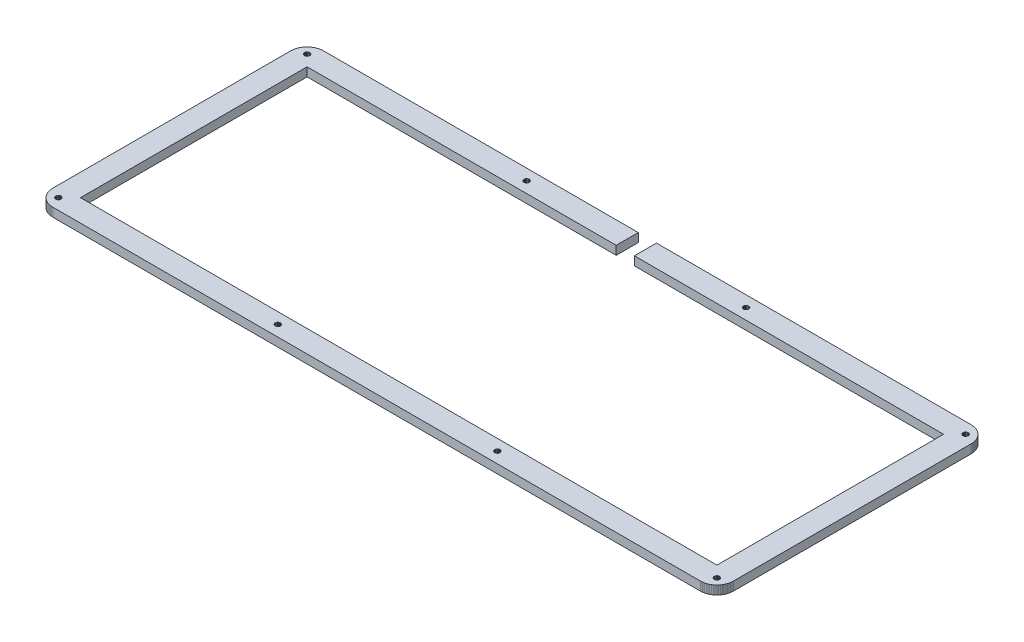
from build123d import *

# Parameters (mm, degrees)
BOSS_EXTRUDE1_DEPTH = 4.7625


with BuildPart() as part:
    # Sketch1 → Boss-Extrude1 (new body)
    with BuildSketch(Plane(origin=(0, 0, 0), x_dir=(1, 0, 0), z_dir=(0, 1, 0))):
        Polygon((180.976, 147.968), (180.976, 135.919), (12.1447, 135.919), (12.1447, 12.1405), (359.759, 12.1405), (359.759, 135.919), (190.926, 135.919), (190.926, 147.967), (362.807, 147.967), (363.513, 147.941), (364.215, 147.857), (364.91, 147.719), (365.591, 147.527), (366.254, 147.282), (366.896, 146.987), (367.51, 146.641), (368.099, 146.25), (368.653, 145.812), (369.171, 145.331), (369.651, 144.812), (370.089, 144.259), (370.48, 143.67), (370.826, 143.053), (371.122, 142.412), (371.369, 141.749), (371.56, 141.07), (371.697, 140.375), (371.778, 139.674), (371.807, 138.967), (371.807, 9.09091), (371.778, 8.38535), (371.697, 7.68396), (371.56, 6.99079), (371.369, 6.31003), (371.122, 5.6472), (370.826, 5.00641), (370.48, 4.38905), (370.089, 3.80062), (369.651, 3.24666), (369.171, 2.72852), (368.653, 2.24758), (368.099, 1.81074), (367.51, 1.418), (366.896, 1.07211), (366.254, 0.777215), (365.591, 0.531922), (364.91, 0.340376), (364.215, 0.202572), (363.513, 0.118511), (362.807, 0.0909507), (9.09507, 0.0909507), (8.3881, 0.118511), (7.68671, 0.202572), (6.99216, 0.340376), (6.31278, 0.531922), (5.64995, 0.777215), (5.00916, 1.07211), (4.3918, 1.418), (3.8034, 1.81074), (3.24942, 2.24758), (2.73127, 2.72852), (2.25034, 3.24666), (1.81212, 3.80062), (1.42076, 4.38905), (1.07487, 5.00641), (0.77997, 5.6472), (0.534681, 6.31003), (0.343131, 6.99079), (0.205328, 7.68396), (0.121267, 8.38535), (0.0937066, 9.09228), (0.0950846, 138.967), (0.121267, 139.674), (0.205328, 140.375), (0.343131, 141.07), (0.534681, 141.749), (0.77997, 142.412), (1.07487, 143.053), (1.42076, 143.67), (1.81212, 144.259), (2.25034, 144.812), (2.73127, 145.331), (3.24942, 145.812), (3.8034, 146.25), (4.3918, 146.641), (5.00916, 146.987), (5.64995, 147.282), (6.31278, 147.527), (6.99216, 147.719), (7.68671, 147.857), (8.3881, 147.941), (9.09507, 147.968), align=None)
        Polygon((365.326, 7.51858), (364.917, 7.31188), (364.589, 6.98253), (364.381, 6.57186), (364.307, 6.11572), (364.381, 5.66099), (364.589, 5.25032), (364.917, 4.92372), (365.326, 4.71428), (365.781, 4.64125), (366.24, 4.71428), (366.649, 4.92372), (366.977, 5.25032), (367.185, 5.66099), (367.259, 6.11572), (367.185, 6.57186), (366.977, 6.98253), (366.649, 7.31188), (366.24, 7.51858), (365.781, 7.5916), align=None, mode=Mode.SUBTRACT)
        Polygon((245.438, 7.51858), (245.027, 7.31188), (244.703, 6.98253), (244.492, 6.57186), (244.42, 6.11572), (244.492, 5.66099), (244.703, 5.25032), (245.027, 4.92372), (245.438, 4.71428), (245.894, 4.64125), (246.35, 4.71428), (246.761, 4.92372), (247.088, 5.25032), (247.297, 5.66099), (247.37, 6.11572), (247.297, 6.57186), (247.088, 6.98253), (246.761, 7.31188), (246.35, 7.51858), (245.894, 7.5916), align=None, mode=Mode.SUBTRACT)
        Polygon((125.552, 7.51858), (125.138, 7.31188), (124.815, 6.98253), (124.604, 6.57186), (124.532, 6.11572), (124.604, 5.66099), (124.815, 5.25032), (125.138, 4.92372), (125.552, 4.71428), (126.007, 4.64125), (126.463, 4.71428), (126.873, 4.92372), (127.201, 5.25032), (127.409, 5.66099), (127.482, 6.11572), (127.409, 6.57186), (127.201, 6.98253), (126.873, 7.31188), (126.463, 7.51858), (126.007, 7.5916), align=None, mode=Mode.SUBTRACT)
        Polygon((5.66374, 7.51858), (5.25307, 7.31188), (4.9251, 6.98253), (4.71703, 6.57186), (4.644, 6.11572), (4.71703, 5.66099), (4.9251, 5.25032), (5.25307, 4.92372), (5.66374, 4.71428), (6.11851, 4.64125), (6.57461, 4.71428), (6.98528, 4.92372), (7.31326, 5.25032), (7.52133, 5.66099), (7.59435, 6.11572), (7.52133, 6.57186), (7.31326, 6.98253), (6.98528, 7.31188), (6.57461, 7.51858), (6.11851, 7.5916), align=None, mode=Mode.SUBTRACT)
        Polygon((125.552, 143.345), (125.138, 143.137), (124.815, 142.809), (124.604, 142.398), (124.532, 141.942), (124.604, 141.487), (124.815, 141.077), (125.138, 140.75), (125.552, 140.541), (126.007, 140.468), (126.463, 140.541), (126.873, 140.75), (127.201, 141.077), (127.409, 141.487), (127.482, 141.942), (127.409, 142.398), (127.201, 142.809), (126.873, 143.137), (126.463, 143.345), (126.007, 143.417), align=None, mode=Mode.SUBTRACT)
        Polygon((245.438, 143.345), (245.027, 143.137), (244.703, 142.809), (244.492, 142.398), (244.42, 141.942), (244.492, 141.487), (244.703, 141.077), (245.027, 140.75), (245.438, 140.541), (245.894, 140.468), (246.35, 140.541), (246.761, 140.75), (247.088, 141.077), (247.297, 141.487), (247.37, 141.942), (247.297, 142.398), (247.088, 142.809), (246.761, 143.137), (246.35, 143.345), (245.894, 143.417), align=None, mode=Mode.SUBTRACT)
        Polygon((365.326, 143.345), (364.917, 143.137), (364.589, 142.809), (364.381, 142.398), (364.307, 141.942), (364.381, 141.487), (364.589, 141.077), (364.917, 140.75), (365.326, 140.541), (365.781, 140.468), (366.24, 140.541), (366.649, 140.75), (366.977, 141.077), (367.185, 141.487), (367.259, 141.942), (367.185, 142.398), (366.977, 142.809), (366.649, 143.137), (366.24, 143.345), (365.781, 143.417), align=None, mode=Mode.SUBTRACT)
        Polygon((5.66374, 143.345), (5.25307, 143.137), (4.9251, 142.809), (4.71703, 142.398), (4.644, 141.942), (4.71703, 141.487), (4.9251, 141.077), (5.25307, 140.75), (5.66374, 140.541), (6.11851, 140.468), (6.57461, 140.541), (6.98528, 140.75), (7.31326, 141.077), (7.52133, 141.487), (7.59435, 141.942), (7.52133, 142.398), (7.31326, 142.809), (6.98528, 143.137), (6.57461, 143.345), (6.11851, 143.417), align=None, mode=Mode.SUBTRACT)
    extrude(amount=BOSS_EXTRUDE1_DEPTH)


solid = part.part
